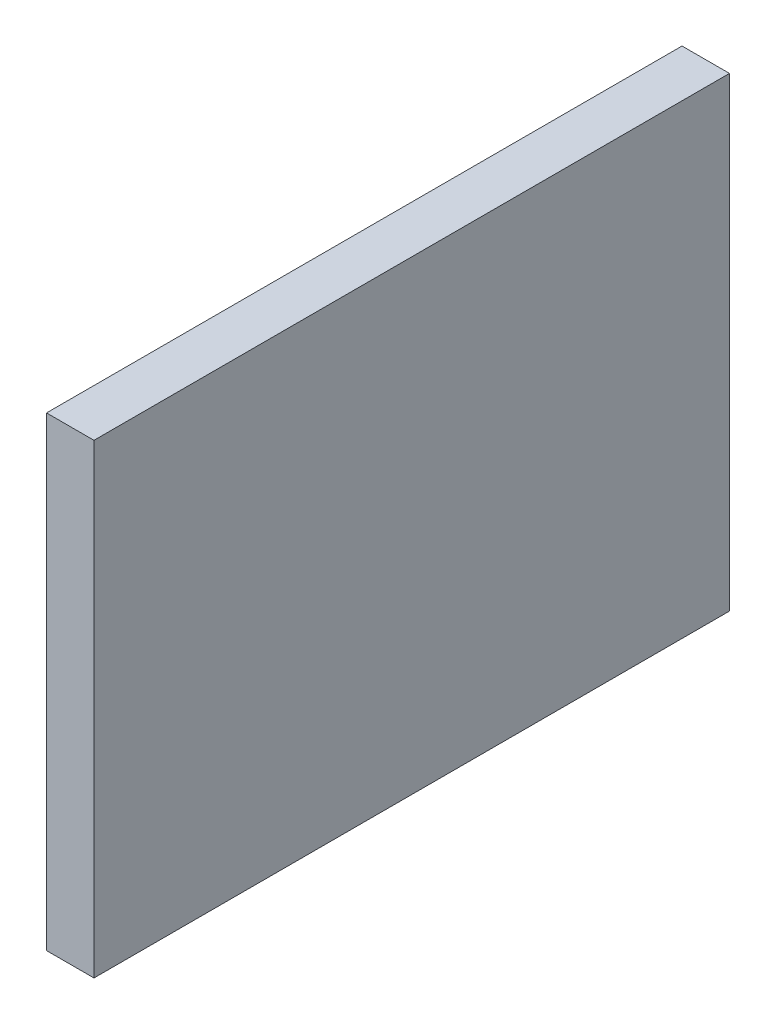
from build123d import *

# Parameters (mm, degrees)
SKETCH1_W           = 147.32
SKETCH1_H           = 107.95
BOSS_EXTRUDE1_DEPTH = 11


with BuildPart() as part:
    # Sketch1 → Boss-Extrude1 (new body)
    with BuildSketch(Plane(origin=(0, 0, 0), x_dir=(0, 0, -1), z_dir=(1, 0, 0))):
        Rectangle(SKETCH1_W, SKETCH1_H)
    extrude(amount=-BOSS_EXTRUDE1_DEPTH)


solid = part.part
